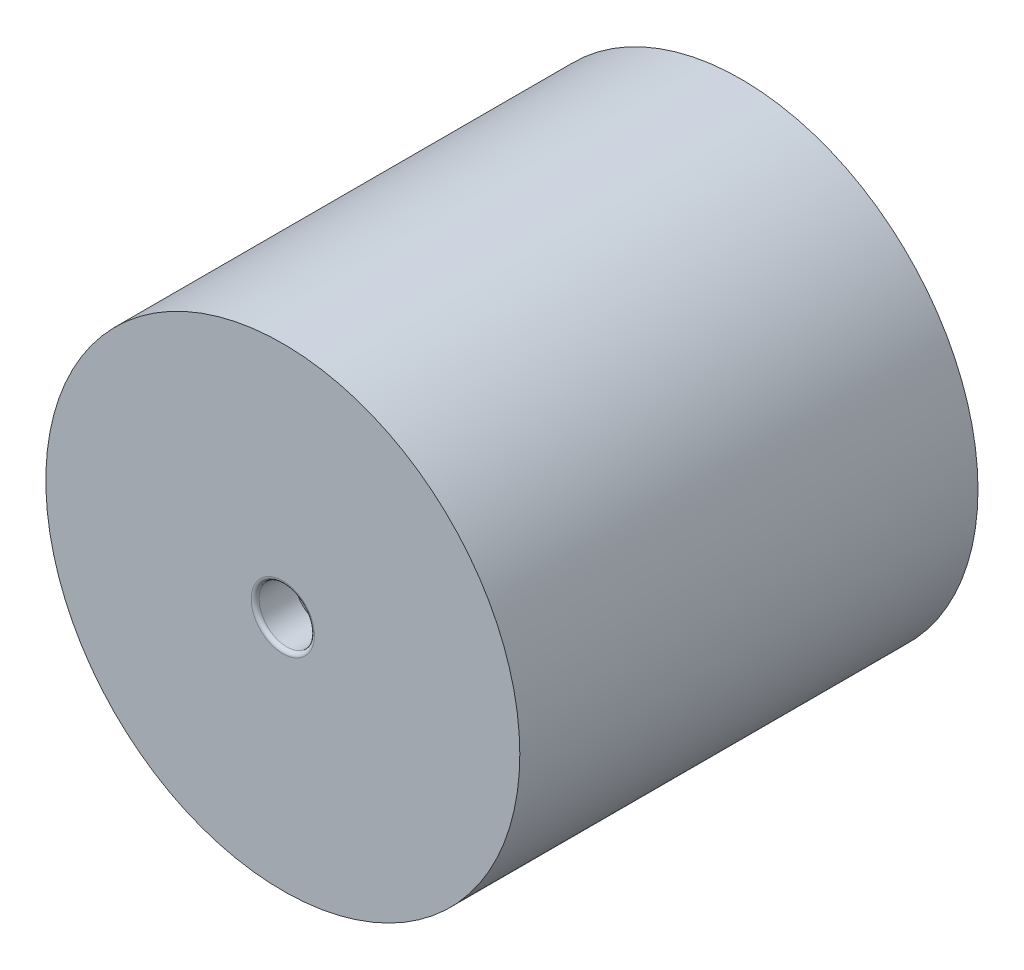
from build123d import *

# Parameters (mm, degrees)
SKETCH21_R           = 30
BOSS_EXTRUDE14_DEPTH = 29
SKETCH24_R           = 3.5
CUT_EXTRUDE1_DEPTH   = 5
SKETCH25_R           = 3.5
CUT_EXTRUDE2_DEPTH   = 5
FILLET1_R            = 0.5


with BuildPart() as part:
    # Sketch21 → Boss-Extrude14 (new body, symmetric)
    with BuildSketch(Plane.XY):
        Circle(SKETCH21_R)
    extrude(amount=BOSS_EXTRUDE14_DEPTH, both=True)

    # Sketch24 → Cut-Extrude1 (cut)
    with BuildSketch(Plane(origin=(0, 0, -29), x_dir=(-1, 0, 0), z_dir=(0, 0, -1))):
        Circle(SKETCH24_R)
    extrude(amount=-CUT_EXTRUDE1_DEPTH, mode=Mode.SUBTRACT)

    # Sketch25 → Cut-Extrude2 (cut)
    with BuildSketch(Plane.XY.offset(29)):
        with Locations(Location((0, 0, 0), (0, 0, 180))):  # turned: the seam where the file's is
            Circle(SKETCH25_R)
    extrude(amount=-CUT_EXTRUDE2_DEPTH, mode=Mode.SUBTRACT)

    # Fillet1
    fillet1_edges = [part.edges().sort_by_distance(p)[0] for p in [
        (3.5, 0, 29),
        (3.5, 0, -29),
    ]]
    fillet(fillet1_edges, radius=FILLET1_R)


solid = part.part
